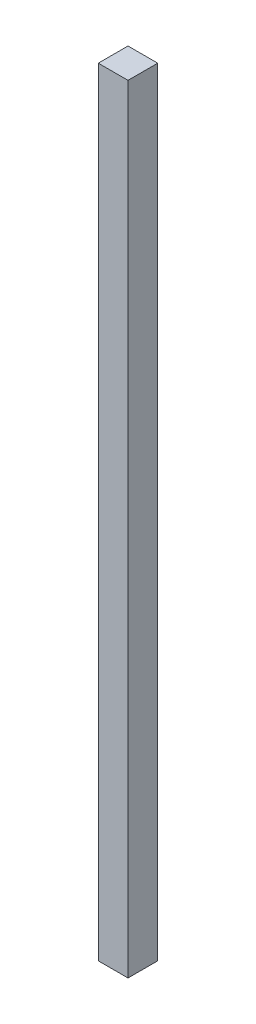
from build123d import *

# Parameters (mm, degrees)
SKETCH1_W           = 88.9
SKETCH1_H           = 88.9
BOSS_EXTRUDE1_DEPTH = 2324.1


with BuildPart() as part:
    # Sketch1 → Boss-Extrude1 (new body)
    with BuildSketch(Plane(origin=(0, 0, 0), x_dir=(1, 0, 0), z_dir=(0, 1, 0))):
        Rectangle(SKETCH1_W, SKETCH1_H)
    extrude(amount=BOSS_EXTRUDE1_DEPTH)


solid = part.part
